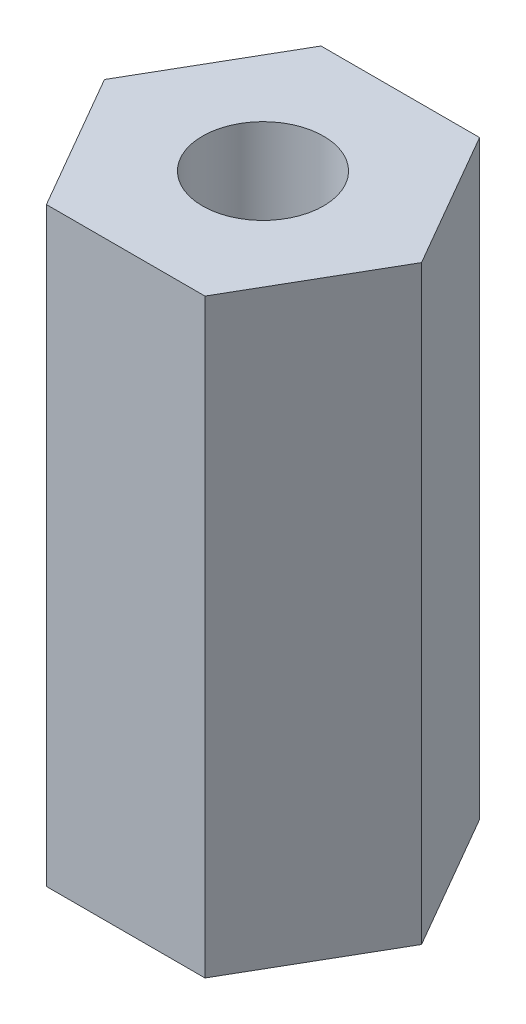
from build123d import *

# Parameters (mm, degrees)
BOSS_EXTRUDE1_DEPTH          = 10
M2_5X0_45_TAPPED_HOLE1_D     = 2.05
M2_5X0_45_TAPPED_HOLE1_DEPTH = 25
M2_5X0_45_TAPPED_HOLE1_TIP   = 0.615882135


with BuildPart() as part:
    # Sketch1 → Boss-Extrude1 (new body)
    with BuildSketch(Plane(origin=(0, 0, 0), x_dir=(1, 0, 0), z_dir=(0, 1, 0))):
        Polygon((2.684678752, 0), (1.342339376, 2.325), (-1.342339376, 2.325), (-2.684678752, 0), (-1.342339376, -2.325), (1.342339376, -2.325), align=None)
    extrude(amount=BOSS_EXTRUDE1_DEPTH)

    # M2.5x0.45 Tapped Hole1
    with Locations(Plane(origin=(0, 10, 0), x_dir=(1, 0, 0), z_dir=(0, 1, 0))):
        with Locations((0, 0)):
            Hole(M2_5X0_45_TAPPED_HOLE1_D / 2, depth=M2_5X0_45_TAPPED_HOLE1_DEPTH)
            with Locations((0, 0, -(M2_5X0_45_TAPPED_HOLE1_DEPTH + M2_5X0_45_TAPPED_HOLE1_TIP / 2))):  # 118° drill point
                Cone(0, M2_5X0_45_TAPPED_HOLE1_D / 2, M2_5X0_45_TAPPED_HOLE1_TIP, mode=Mode.SUBTRACT)


solid = part.part
